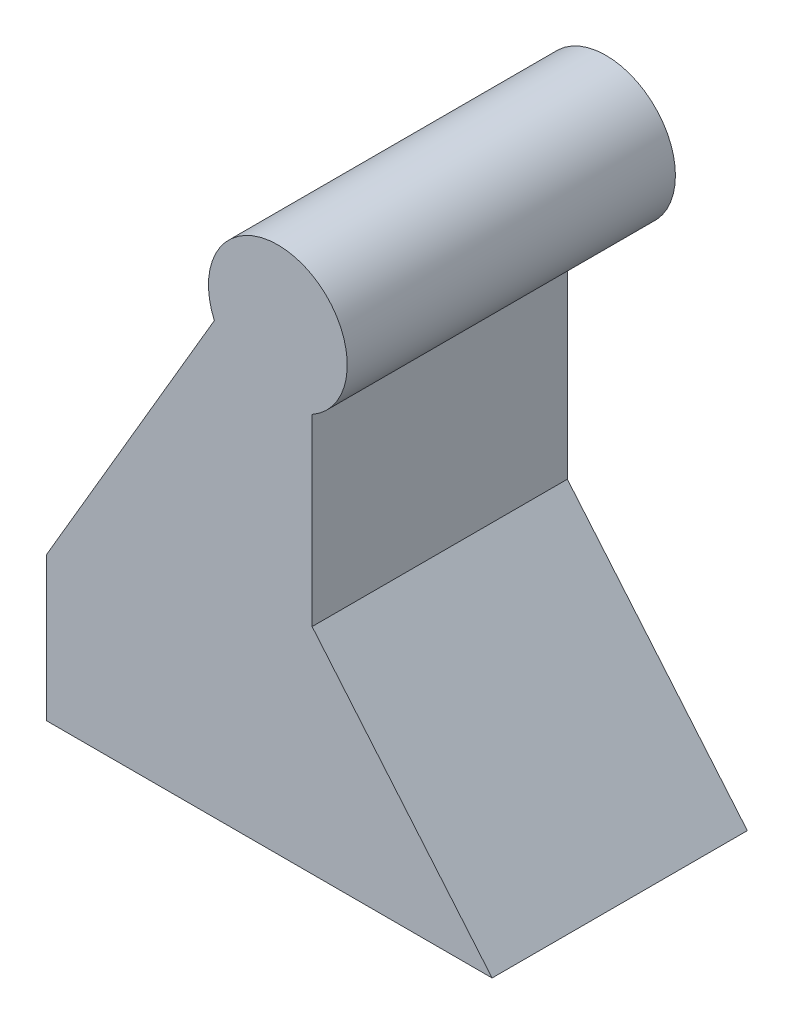
from build123d import *

# Parameters (mm, degrees)
SKETCH1_R           = 9.516746653
SKETCH1_R_2         = 4.309736146
EXTRUDE1_DEPTH      = 10
EXTRUDE1_DEPTH_BACK = 10
EXTRUDE2_DEPTH      = 25
EXTRUDE2_DEPTH_BACK = 10
EXTRUDE3_DEPTH      = 25


with BuildPart() as part:
    # Sketch1 → Extrude1 (new body, two sides)
    with BuildSketch(Plane.XY) as extrude1_sk:
        with Locations((-74.315769624, -7.949999587)):
            Circle(SKETCH1_R)
        with Locations((-74.315769624, -7.949999587)):
            Circle(SKETCH1_R_2, mode=Mode.SUBTRACT)
    extrude(amount=EXTRUDE1_DEPTH)
    extrude(extrude1_sk.sketch, amount=-EXTRUDE1_DEPTH_BACK)

    # Sketch2 → Extrude2 (add, two sides)
    with BuildSketch(Plane.XY.offset(10)) as extrude2_sk:
        with BuildLine():
            Line((-83.025654753, -11.784887838), (-106.019653855, -51.047339529))
            Line((-106.019653855, -51.047339529), (-106.019653855, -70.815363126))
            Line((-106.019653855, -70.815363126), (-44.938455036, -70.815363126))
            Line((-44.938455036, -70.815363126), (-69.620440041, -41.423398152))
            Line((-69.620440041, -41.423398152), (-69.620440041, -16.227822185))
            ThreePointArc((-69.620440041, -16.227822185), (-77.309777049, -16.983514208), (-83.025654753, -11.784887838))
        make_face()
    extrude(amount=EXTRUDE2_DEPTH)
    extrude(extrude2_sk.sketch, amount=-EXTRUDE2_DEPTH_BACK)

    # Sketch3 → Extrude3 (add)
    with BuildSketch(Plane.XY.offset(10)):
        with BuildLine():
            ThreePointArc((-83.025654753, -11.784887838), (-77.309777049, -16.983514208), (-69.620440041, -16.227822185))
            ThreePointArc((-69.620440041, -16.227822185), (-71.321762199, 1.083515033), (-83.025654753, -11.784887838))
        make_face()
    extrude(amount=EXTRUDE3_DEPTH)


solid = part.part
